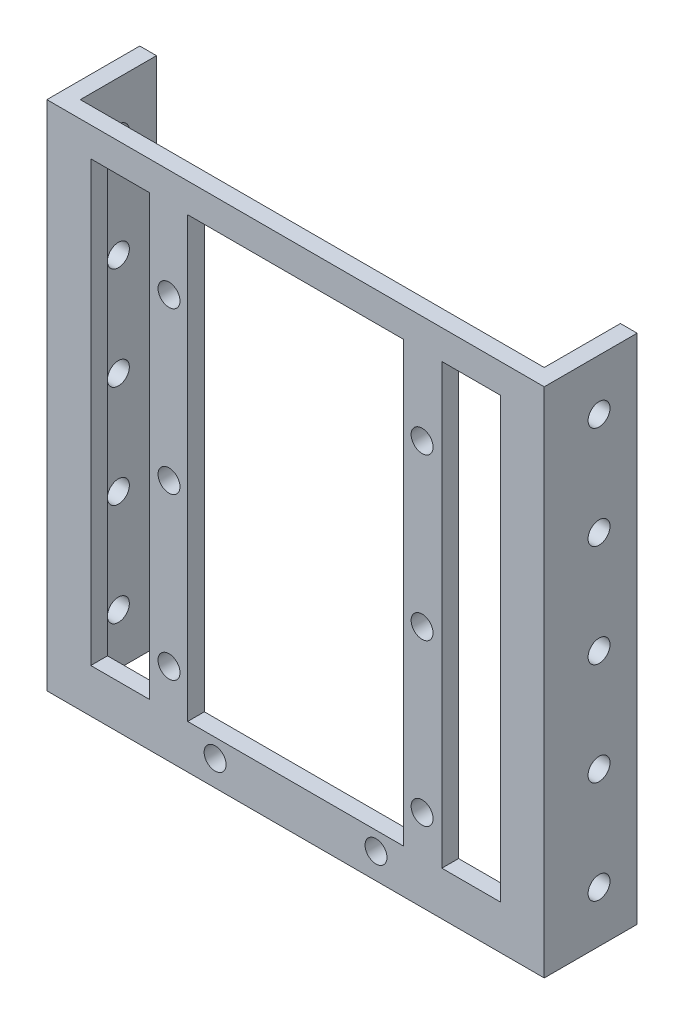
from build123d import *

# Parameters (mm, degrees)
SKETCH1_W             = 41.5
SKETCH1_H             = 70
SKETCH1_R             = 1.5
SKETCH1_W_2           = 29.5
SKETCH1_H_2           = 60
BOSS_EXTRUDE1_DEPTH   = 1.143
SKETCH2_W             = 13.25
SKETCH2_H             = 70
BOSS_EXTRUDE2_DEPTH   = 2.286
SKETCH8_W             = 8
SKETCH8_H             = 60
CUT_EXTRUDE1_DEPTH    = 10
SKETCH9_W             = 2.286
SKETCH9_H             = 70
BOSS_EXTRUDE3_DEPTH   = 10.414
F_3_0MM_DOWEL_HOLE1_D = 3


with BuildPart() as part:
    # Sketch1 → Boss-Extrude1 (new body, symmetric)
    with BuildSketch(Plane.XY):
        with Locations((0, 35)):
            Rectangle(SKETCH1_W, SKETCH1_H)
        with Locations((-17.3, 11.25)):
            Circle(SKETCH1_R, mode=Mode.SUBTRACT)
        with Locations((-11, 3.5)):
            Circle(SKETCH1_R, mode=Mode.SUBTRACT)
        with Locations((-17.3, 33.25)):
            Circle(SKETCH1_R, mode=Mode.SUBTRACT)
        with Locations((-17.3, 55.25)):
            Circle(SKETCH1_R, mode=Mode.SUBTRACT)
        with Locations((17.3, 55.25)):
            Circle(SKETCH1_R, mode=Mode.SUBTRACT)
        with Locations((17.3, 33.25)):
            Circle(SKETCH1_R, mode=Mode.SUBTRACT)
        with Locations((11, 3.5)):
            Circle(SKETCH1_R, mode=Mode.SUBTRACT)
        with Locations((17.3, 11.25)):
            Circle(SKETCH1_R, mode=Mode.SUBTRACT)
        with Locations((0, 36)):
            Rectangle(SKETCH1_W_2, SKETCH1_H_2, mode=Mode.SUBTRACT)
    extrude(amount=BOSS_EXTRUDE1_DEPTH, both=True)

    # Sketch2 → Boss-Extrude2 (add)
    with BuildSketch(Plane.XY.offset(1.143)):
        with Locations((-27.375, 35)):
            Rectangle(SKETCH2_W, SKETCH2_H)
    boss_extrude2 = extrude(amount=-BOSS_EXTRUDE2_DEPTH)

    # Mirror4: Boss-Extrude2 across plane
    add(boss_extrude2.mirror(Plane(origin=(0, 0, 0), x_dir=(0, 0, 1), z_dir=(1, 0, 0))))

    # Sketch8 → Cut-Extrude1 (cut)
    with BuildSketch(Plane.XY.offset(1.143)):
        with Locations((-24, 36)):
            Rectangle(SKETCH8_W, SKETCH8_H)
    cut_extrude1 = extrude(amount=-CUT_EXTRUDE1_DEPTH, mode=Mode.SUBTRACT)

    # Mirror3: Cut-Extrude1 across plane
    add(cut_extrude1.mirror(Plane(origin=(0, 0, 0), x_dir=(0, 0, 1), z_dir=(1, 0, 0))), mode=Mode.SUBTRACT)

    # Sketch9 → Boss-Extrude3 (add)
    with BuildSketch(Plane(origin=(0, 0, -1.143), x_dir=(-1, 0, 0), z_dir=(0, 0, -1))):
        with Locations((32.857, 35)):
            Rectangle(SKETCH9_W, SKETCH9_H)
    boss_extrude3 = extrude(amount=BOSS_EXTRUDE3_DEPTH)

    # Mirror5: Boss-Extrude3 across plane
    add(boss_extrude3.mirror(Plane(origin=(0, 0, 0), x_dir=(0, 0, 1), z_dir=(1, 0, 0))))

    # Ø3.0mm Dowel Hole1 (through all)
    with Locations(Plane.ZY.offset(34)):
        with Locations((-6.35, 35), (-6.35, 21), (-6.35, 49), (-6.35, 63), (-6.35, 7)):
            Hole(F_3_0MM_DOWEL_HOLE1_D / 2)


solid = part.part
